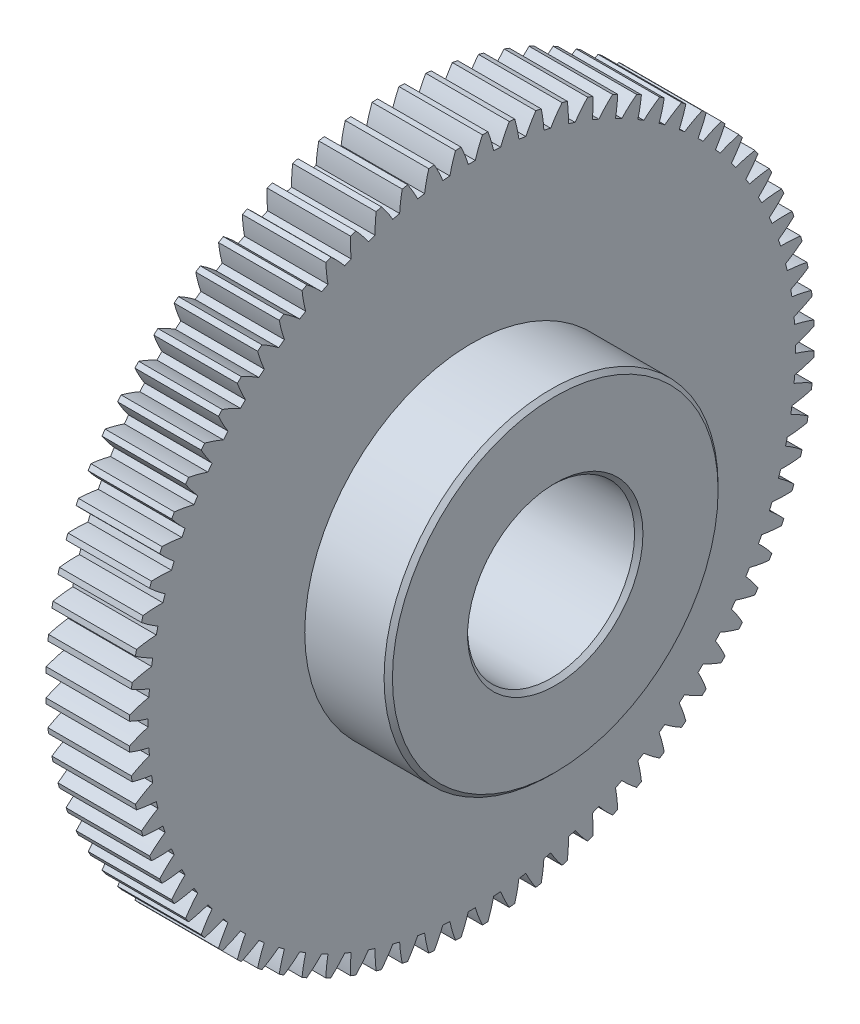
from build123d import *

# Parameters (mm, degrees)
BASPROSKE_W     = 10
BASPROSKE_H     = 41
TOOTHCUT_DEPTH  = 59.838762733
TEETHCUTS_COUNT = 80
TEETHCUTS_ANGLE = 355.5
SKETCH_1_R      = 20
EXTRUDE_1_DEPTH = 10
BORSKE_R        = 10
BORE_DEPTH      = 50.0000508
CHAMFER_1_SIZE  = 0.5


with BuildPart() as part:
    # BasProSke → Base-Revolve (revolve)
    with BuildSketch(Plane(origin=(0, 0, 0), x_dir=(1, 0, 0), z_dir=(0, 1, 0)), mode=Mode.PRIVATE) as base_revolve_sk:
        with Locations((5, 20.5)):
            Rectangle(BASPROSKE_W, BASPROSKE_H)
    revolve(base_revolve_sk.sketch.rotate(Axis((-10, 0, 0), (1, 0, 0)), 180), axis=Axis((-10, 0, 0), (1, 0, 0)))

    # TooCutSke → ToothCut (cut, through all)
    with BuildSketch(Plane(origin=(0, 0, 0), x_dir=(0, 0, -1), z_dir=(1, 0, 0))):
        with BuildLine():
            ThreePointArc((0.420555483, 38.74671772), (0, 38.749), (-0.420555483, 38.74671772))
            ThreePointArc((-0.420555483, 38.74671772), (-0.81345102, 39.892387293), (-1.291883564, 41.005054347))
            ThreePointArc((-1.291883564, 41.005054347), (0, 41.0254), (1.291883564, 41.005054347))
            ThreePointArc((1.291883564, 41.005054347), (0.81345102, 39.892387293), (0.420555483, 38.74671772))
        make_face()
    toothcut = extrude(amount=TOOTHCUT_DEPTH, mode=Mode.SUBTRACT)

    # TeethCuts: ToothCut ×80 about axis
    teethcuts_axis = Axis((-10, 0, 0), (1, 0, 0))
    for i in range(1, TEETHCUTS_COUNT):
        add(toothcut.rotate(teethcuts_axis, i * TEETHCUTS_ANGLE / (TEETHCUTS_COUNT - 1)), mode=Mode.SUBTRACT)

    # 草圖1 → 填料-伸長1 (add)
    with BuildSketch(Plane(origin=(10, 0, 0), x_dir=(0, 0, -1), z_dir=(1, 0, 0))):
        with Locations(Location((0, 0, 0), (0, 0, 180))):
            Circle(SKETCH_1_R)
    extrude(amount=EXTRUDE_1_DEPTH)

    # BorSke → Bore (cut, symmetric)
    with BuildSketch(Plane(origin=(0, 0, 0), x_dir=(0, 0, -1), z_dir=(1, 0, 0))):
        Circle(BORSKE_R)
    extrude(amount=BORE_DEPTH, both=True, mode=Mode.SUBTRACT)

    # 導角1
    chamfer_1_edges = [part.edges().sort_by_distance(p)[0] for p in [
        (20, 0, -20),
        (20, 0, 10),
        (0, 0, 10),
    ]]
    chamfer(chamfer_1_edges, length=CHAMFER_1_SIZE)


solid = part.part
